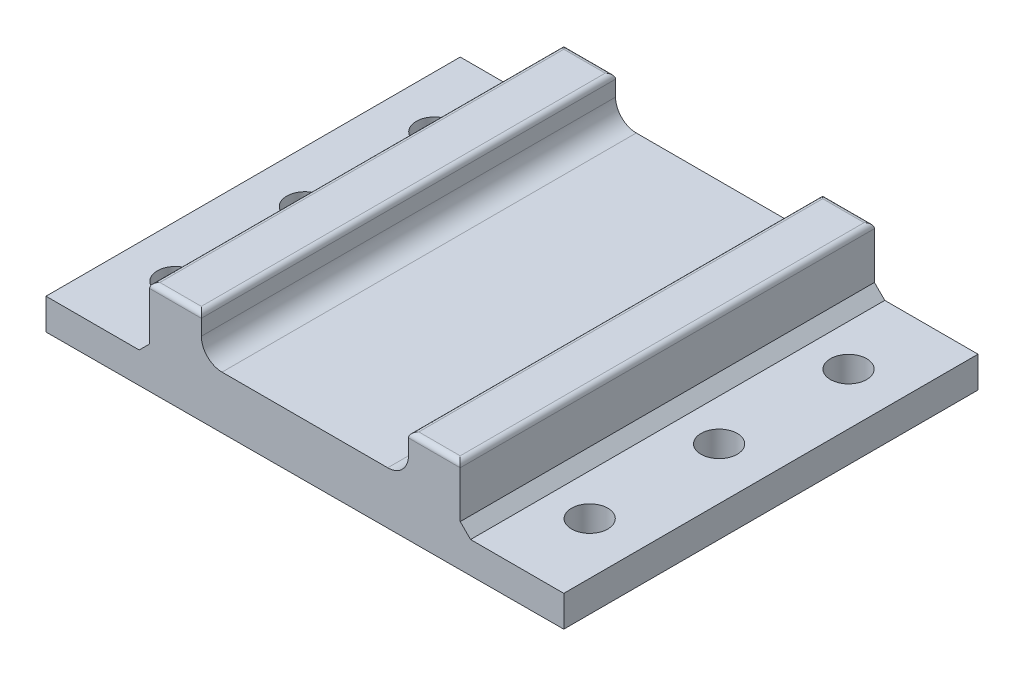
from build123d import *

# Parameters (mm, degrees)
BOSS_EXTRU_3_DEPTH      = 80
ESQUISSE17_R            = 3.5
ENL_V_MAT_EXTRU_4_DEPTH = 7
ESQUISSE18_R            = 3.5
ENL_V_MAT_EXTRU_5_DEPTH = 7.298921418
CHANFREIN5_SIZE         = 2
CONG_1_R                = 4
CONG_2_R                = 1


with BuildPart() as part:
    # Esquisse16 → Boss.-Extru.3 (new body)
    with BuildSketch(Plane.XY):
        Polygon((0, 0), (10, 0), (10, -8), (50, -8), (50, 0), (60, 0), (60, -12), (80, -12), (80, -18), (-20, -18.298921418), (-20, -12.298921418), (0, -12.298921418), align=None)
    extrude(amount=-BOSS_EXTRU_3_DEPTH)

    # Esquisse17 → Enlèv. mat.-Extru.4 (cut, through all)
    with BuildSketch(Plane(origin=(0, -12.298921418, 0), x_dir=(1, 0, 0), z_dir=(0, 1, 0))):
        with Locations((-10, 65)):
            Circle(ESQUISSE17_R)
        with Locations((-10, 40)):
            Circle(ESQUISSE17_R)
        with Locations((-10, 15)):
            Circle(ESQUISSE17_R)
    extrude(amount=-ENL_V_MAT_EXTRU_4_DEPTH, mode=Mode.SUBTRACT)

    # Esquisse18 → Enlèv. mat.-Extru.5 (cut, through all)
    with BuildSketch(Plane(origin=(0, -12, 0), x_dir=(1, 0, 0), z_dir=(0, 1, 0))):
        with Locations((70, 65)):
            Circle(ESQUISSE18_R)
        with Locations((70, 40)):
            Circle(ESQUISSE18_R)
        with Locations((70, 15)):
            Circle(ESQUISSE18_R)
    extrude(amount=-ENL_V_MAT_EXTRU_5_DEPTH, mode=Mode.SUBTRACT)

    # Chanfrein5
    chanfrein5_edges = [part.edges().sort_by_distance(p)[0] for p in [
        (60, -12, -40),
        (0, -12.298921418, -40),
    ]]
    chamfer(chanfrein5_edges, length=CHANFREIN5_SIZE)

    # Congé1
    cong_1_edges = [part.edges().sort_by_distance(p)[0] for p in [
        (10, -8, -40),
        (50, -8, -40),
    ]]
    fillet(cong_1_edges, radius=CONG_1_R)

    # Congé2
    cong_2_edges = [part.edges().sort_by_distance(p)[0] for p in [
        (5, 0, 0),
        (55, 0, 0),
        (0, 0, -40),
        (10, 0, -40),
        (50, 0, -40),
        (60, 0, -40),
        (55, 0, -80),
        (5, 0, -80),
    ]]
    fillet(cong_2_edges, radius=CONG_2_R)


solid = part.part
